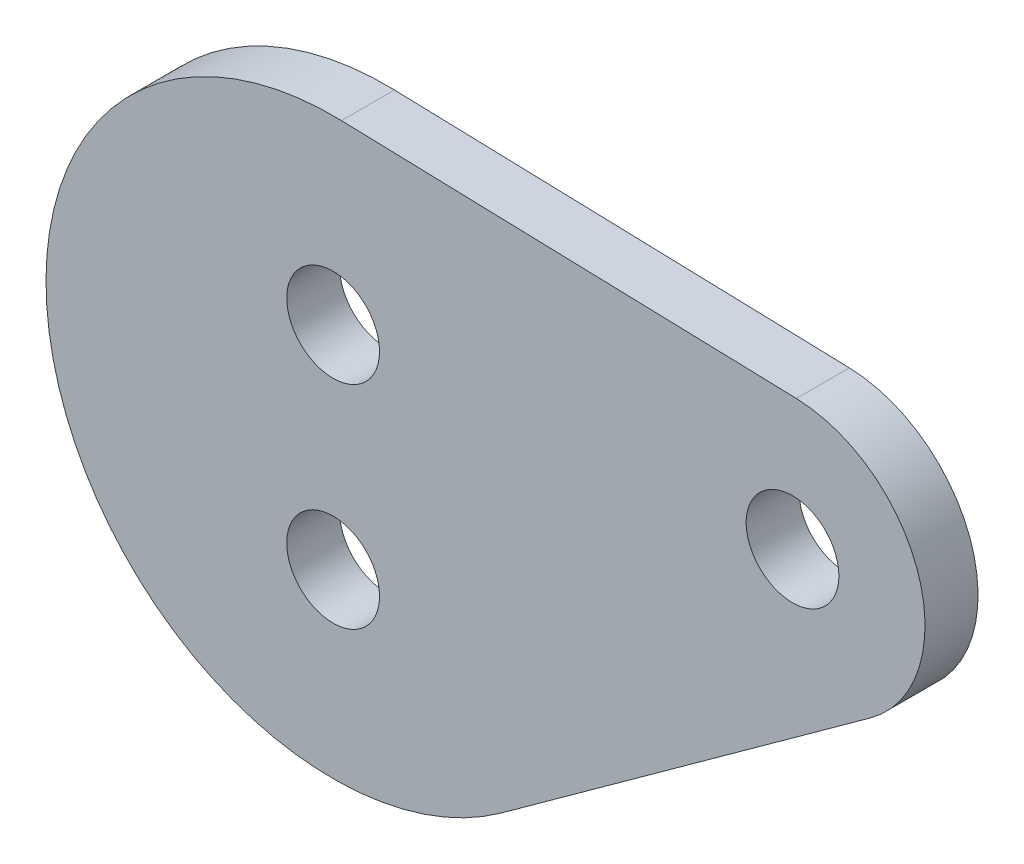
from build123d import *

# Parameters (mm, degrees)
SKETCH1_R      = 5.25
EXTRUDE1_DEPTH = 6


with BuildPart() as part:
    # Sketch1 → Extrude1 (new body)
    with BuildSketch(Plane.XY):
        with BuildLine():
            Line((0.941698735, 32.486354112), (52.434630185, 30.993701898))
            ThreePointArc((52.434630185, 30.993701898), (66.336685131, 20.411287733), (60.788342788, 3.84413594))
            Line((60.788342788, 3.84413594), (19.041409373, -26.337705463))
            ThreePointArc((19.041409373, -26.337705463), (-31.062817783, -9.557790087), (0.941698735, 32.486354112))
        make_face()
        with Locations((0, 12)):
            Circle(SKETCH1_R, mode=Mode.SUBTRACT)
        with Locations((0, -12)):
            Circle(SKETCH1_R, mode=Mode.SUBTRACT)
        with Locations((52, 16)):
            Circle(SKETCH1_R, mode=Mode.SUBTRACT)
    extrude(amount=EXTRUDE1_DEPTH)


solid = part.part
